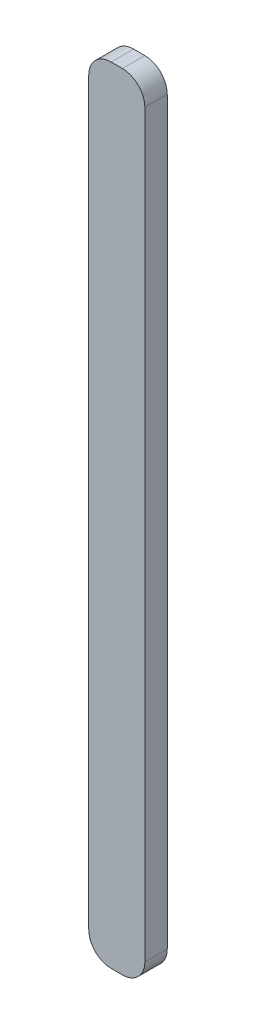
from build123d import *

# Parameters (mm, degrees)
BOSS_EXTRUDE1_DEPTH = 1


with BuildPart() as part:
    # Sketch1 → Boss-Extrude1 (new body)
    with BuildSketch(Plane.XY):
        with BuildLine():
            Line((-0.25, 17.5), (0.25, 17.5))
            ThreePointArc((0.25, 17.5), (0.957106781, 17.207106781), (1.25, 16.5))
            Line((1.25, 16.5), (1.25, -16.5))
            ThreePointArc((1.25, -16.5), (0.957106781, -17.207106781), (0.25, -17.5))
            Line((0.25, -17.5), (-0.25, -17.5))
            ThreePointArc((-0.25, -17.5), (-0.957106781, -17.207106781), (-1.25, -16.5))
            Line((-1.25, -16.5), (-1.25, 16.5))
            ThreePointArc((-1.25, 16.5), (-0.957106781, 17.207106781), (-0.25, 17.5))
        make_face()
    extrude(amount=BOSS_EXTRUDE1_DEPTH)


solid = part.part
